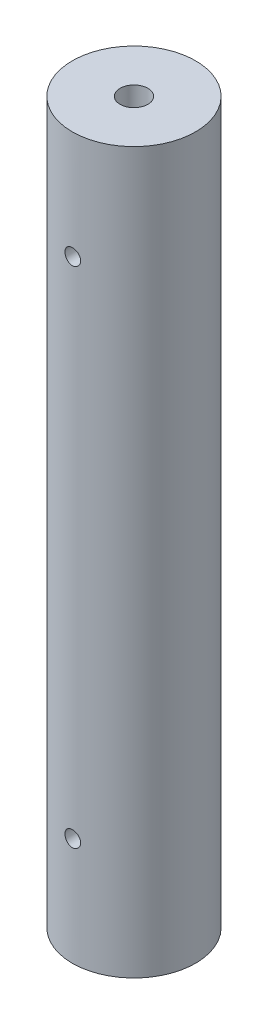
from build123d import *

# Parameters (mm, degrees)
SKETCH1_R                 = 5
BOSS_EXTRUDE1_DEPTH       = 58.42
F_4_40_TAPPED_HOLE1_D     = 2.2606
F_4_40_TAPPED_HOLE1_DEPTH = 9.525
F_4_40_TAPPED_HOLE1_TIP   = 0.679152758
F_4_40_TAPPED_HOLE2_D     = 2.2606
F_4_40_TAPPED_HOLE2_DEPTH = 9.525
F_4_40_TAPPED_HOLE2_TIP   = 0.679152758
SKETCH7_R                 = 0.635
CUT_EXTRUDE1_DEPTH        = 6
CUT_EXTRUDE1_DEPTH_BACK   = 6


with BuildPart() as part:
    # Sketch1 → Boss-Extrude1 (new body)
    with BuildSketch(Plane(origin=(0, 0, 0), x_dir=(1, 0, 0), z_dir=(0, 1, 0))):
        with Locations(Location((0, 0, 0), (0, 0, 270))):  # turned: the seam where the file's is
            Circle(SKETCH1_R)
    extrude(amount=BOSS_EXTRUDE1_DEPTH)

    # #4-40 Tapped Hole1
    with Locations(Plane(origin=(0, 58.42, 0), x_dir=(1, 0, 0), z_dir=(0, 1, 0))):
        with Locations((0, 0)):
            Hole(F_4_40_TAPPED_HOLE1_D / 2, depth=F_4_40_TAPPED_HOLE1_DEPTH)
            with Locations((0, 0, -(F_4_40_TAPPED_HOLE1_DEPTH + F_4_40_TAPPED_HOLE1_TIP / 2))):  # 118° drill point
                Cone(0, F_4_40_TAPPED_HOLE1_D / 2, F_4_40_TAPPED_HOLE1_TIP, mode=Mode.SUBTRACT)

    # #4-40 Tapped Hole2
    with Locations(Plane(origin=(0, 0, 0), x_dir=(-1, 0, 0), z_dir=(0, -1, 0))):
        with Locations((0, 0)):
            Hole(F_4_40_TAPPED_HOLE2_D / 2, depth=F_4_40_TAPPED_HOLE2_DEPTH)
            with Locations((0, 0, -(F_4_40_TAPPED_HOLE2_DEPTH + F_4_40_TAPPED_HOLE2_TIP / 2))):  # 118° drill point
                Cone(0, F_4_40_TAPPED_HOLE2_D / 2, F_4_40_TAPPED_HOLE2_TIP, mode=Mode.SUBTRACT)

    # Sketch7 → Cut-Extrude1 (cut, two sides)
    with BuildSketch(Plane.XY) as cut_extrude1_sk:
        with Locations((0, 49.657)):
            Circle(SKETCH7_R)
        with Locations((0, 8.763)):
            Circle(SKETCH7_R)
    extrude(amount=CUT_EXTRUDE1_DEPTH, mode=Mode.SUBTRACT)
    extrude(cut_extrude1_sk.sketch, amount=-CUT_EXTRUDE1_DEPTH_BACK, mode=Mode.SUBTRACT)


solid = part.part
